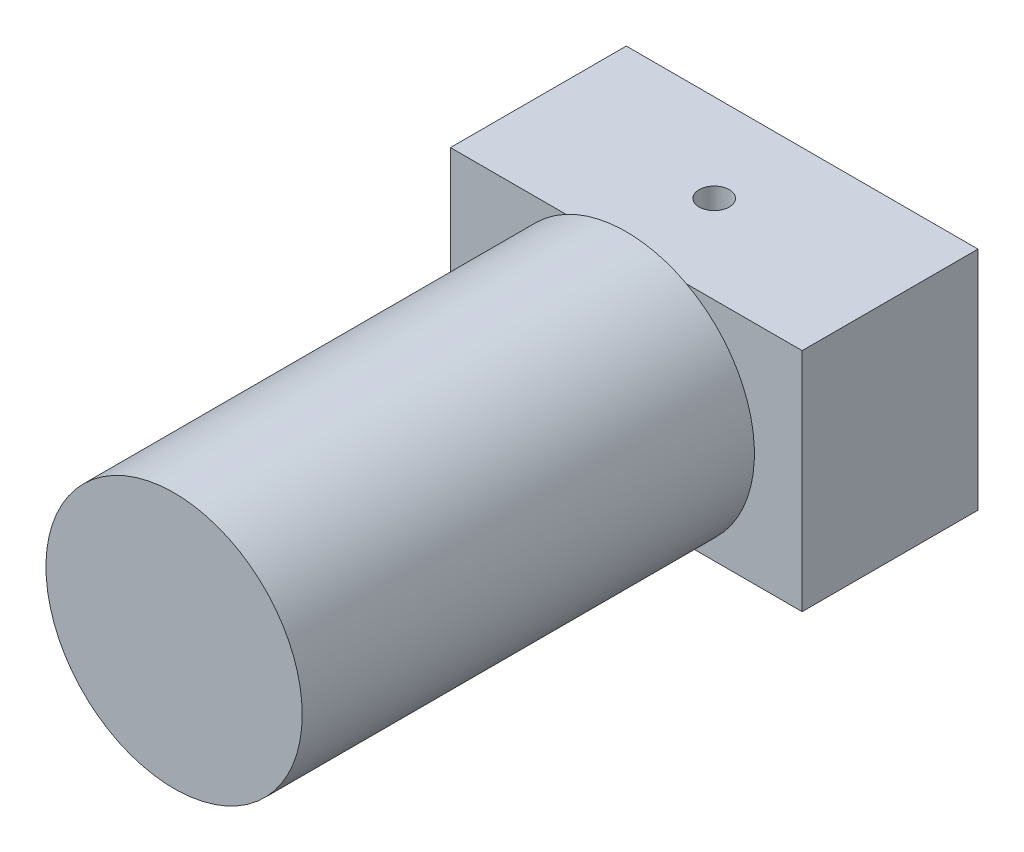
from build123d import *

# Parameters (mm, degrees)
SKETCH1_W           = 70
SKETCH1_H           = 45
BOSS_EXTRUDE1_DEPTH = 35
SKETCH2_R           = 25.5
BOSS_EXTRUDE2_DEPTH = 90
SKETCH3_R           = 3
CUT_EXTRUDE1_DEPTH  = 10


with BuildPart() as part:
    # Sketch1 → Boss-Extrude1 (new body)
    with BuildSketch(Plane.XY):
        Rectangle(SKETCH1_W, SKETCH1_H)
    extrude(amount=BOSS_EXTRUDE1_DEPTH)

    # Sketch2 → Boss-Extrude2 (add)
    with BuildSketch(Plane.XY.offset(35)):
        Circle(SKETCH2_R)
    extrude(amount=BOSS_EXTRUDE2_DEPTH)

    # Sketch3 → Cut-Extrude1 (cut)
    with BuildSketch(Plane(origin=(0, 22.5, 0), x_dir=(1, 0, 0), z_dir=(0, 1, 0))):
        with Locations((0, -17.5)):
            Circle(SKETCH3_R)
    extrude(amount=-CUT_EXTRUDE1_DEPTH, mode=Mode.SUBTRACT)


solid = part.part
